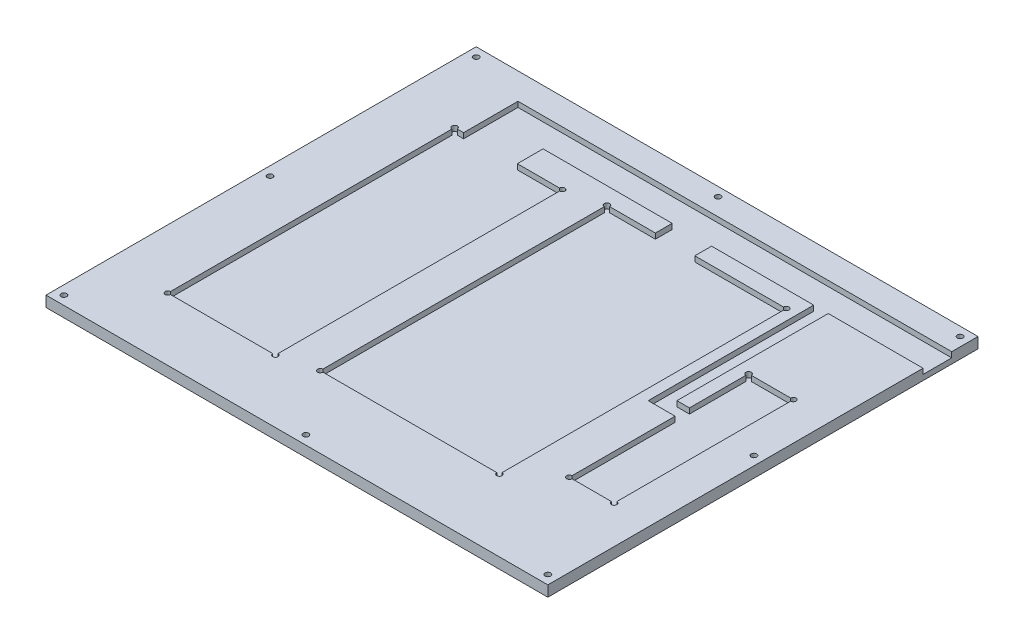
from build123d import *

# Parameters (mm, degrees)
SKETCH_1_W                  = 280
SKETCH_1_H                  = 240
EXTRUDE_1_DEPTH             = 6
HOLE_WIZARD_3_1_3_1_1_D     = 3.1
HOLE_WIZARD_3_1_3_1_1_DEPTH = 10
HOLE_WIZARD_3_1_3_1_1_TIP   = 0.931333959
SKETCH_7_R                  = 1.5
SKETCH_7_W                  = 25
SKETCH_7_H                  = 100
SKETCH_7_W_2                = 100
SKETCH_7_H_2                = 160
SKETCH_7_W_3                = 60
CUT_EXTRUDE_1_DEPTH         = 3
CUT_EXTRUDE_2_DEPTH         = 3


with BuildPart() as part:
    # Эскиз1 → Бобышка-Вытянуть1 (new body)
    with BuildSketch(Plane(origin=(0, 0, 0), x_dir=(1, 0, 0), z_dir=(0, 1, 0))):
        Rectangle(SKETCH_1_W, SKETCH_1_H)
    extrude(amount=EXTRUDE_1_DEPTH)

    # Диаметр отверстия Ø3.1 (3.1)1
    with Locations(Plane(origin=(0, 6, 0), x_dir=(1, 0, 0), z_dir=(0, 1, 0))):
        with Locations((-135, 115), (0, 115), (135, 115), (135, 0), (135, -115), (0, -115), (-135, -115), (-135, 0), (401.523177345, 110.995095939)):
            Hole(HOLE_WIZARD_3_1_3_1_1_D / 2, depth=HOLE_WIZARD_3_1_3_1_1_DEPTH)
            with Locations((0, 0, -(HOLE_WIZARD_3_1_3_1_1_DEPTH + HOLE_WIZARD_3_1_3_1_1_TIP / 2))):  # 118° drill point
                Cone(0, HOLE_WIZARD_3_1_3_1_1_D / 2, HOLE_WIZARD_3_1_3_1_1_TIP, mode=Mode.SUBTRACT)

    # Эскиз7 → Вырез-Вытянуть1 (cut)
    with BuildSketch(Plane(origin=(0, 6, 0), x_dir=(1, 0, 0), z_dir=(0, 1, 0))):
        with BuildLine():
            ThreePointArc((120.5, 38), (119, 39.5), (117.5, 38))
            Line((117.5, 38), (119, 38))
            Line((119, 38), (119, 36.5))
            ThreePointArc((119, 36.5), (120.060660172, 36.939339828), (120.5, 38))
        make_face()
        with BuildLine():
            Line((119, 38), (117.5, 38))
            ThreePointArc((117.5, 38), (117.939339828, 36.939339828), (119, 36.5))
            Line((119, 36.5), (119, 38))
        make_face()
        with Locations((94, 38)):
            Circle(SKETCH_7_R)
        with Locations((94, -62)):
            Circle(SKETCH_7_R)
        with Locations((119, -62)):
            Circle(SKETCH_7_R)
        with Locations((119, 38)):
            Circle(SKETCH_7_R)
        with Locations((106.5, -12)):
            Rectangle(SKETCH_7_W, SKETCH_7_H)
        with BuildLine():
            ThreePointArc((94, 36.5), (95.060660172, 36.939339828), (95.5, 38))
            Line((95.5, 38), (94, 38))
            Line((94, 38), (94, 36.5))
        make_face()
        with BuildLine():
            Line((94, 38), (95.5, 38))
            ThreePointArc((95.5, 38), (92.939339828, 39.060660172), (94, 36.5))
            Line((94, 36.5), (94, 38))
        make_face()
        with BuildLine():
            ThreePointArc((95.5, -62), (95.060660172, -60.939339828), (94, -60.5))
            Line((94, -60.5), (94, -62))
            Line((94, -62), (95.5, -62))
        make_face()
        with BuildLine():
            Line((94, -62), (94, -60.5))
            ThreePointArc((94, -60.5), (92.939339828, -63.060660172), (95.5, -62))
            Line((95.5, -62), (94, -62))
        make_face()
        with BuildLine():
            ThreePointArc((120.5, -62), (120.060660172, -60.939339828), (119, -60.5))
            Line((119, -60.5), (119, -62))
            Line((119, -62), (117.5, -62))
            ThreePointArc((117.5, -62), (119, -63.5), (120.5, -62))
        make_face()
        with BuildLine():
            Line((119, -62), (119, -60.5))
            ThreePointArc((119, -60.5), (117.939339828, -60.939339828), (117.5, -62))
            Line((117.5, -62), (119, -62))
        make_face()
        with Locations((-27, 80)):
            Circle(SKETCH_7_R)
        with Locations((-27, -80)):
            Circle(SKETCH_7_R)
        with Locations((73, -80)):
            Circle(SKETCH_7_R)
        with Locations((73, 80)):
            Circle(SKETCH_7_R)
        with Locations((23, 0)):
            Rectangle(SKETCH_7_W_2, SKETCH_7_H_2)
        with Locations((-107, -85)):
            Circle(SKETCH_7_R)
        with Locations((-47, -85)):
            Circle(SKETCH_7_R)
        with Locations((-47, 75)):
            Circle(SKETCH_7_R)
        with Locations((-107, 75)):
            Circle(SKETCH_7_R)
        with Locations((-77, -5)):
            Rectangle(SKETCH_7_W_3, SKETCH_7_H_2)
        with BuildLine():
            ThreePointArc((74.5, 80), (73, 81.5), (71.5, 80))
            Line((71.5, 80), (73, 80))
            Line((73, 80), (73, 78.5))
            ThreePointArc((73, 78.5), (74.060660172, 78.939339828), (74.5, 80))
        make_face()
        with BuildLine():
            Line((73, 80), (71.5, 80))
            ThreePointArc((71.5, 80), (71.939339828, 78.939339828), (73, 78.5))
            Line((73, 78.5), (73, 80))
        make_face()
        with BuildLine():
            ThreePointArc((74.5, -80), (74.060660172, -78.939339828), (73, -78.5))
            Line((73, -78.5), (73, -80))
            Line((73, -80), (71.5, -80))
            ThreePointArc((71.5, -80), (73, -81.5), (74.5, -80))
        make_face()
        with BuildLine():
            Line((73, -80), (73, -78.5))
            ThreePointArc((73, -78.5), (71.939339828, -78.939339828), (71.5, -80))
            Line((71.5, -80), (73, -80))
        make_face()
        with BuildLine():
            ThreePointArc((-25.5, -80), (-25.939339828, -78.939339828), (-27, -78.5))
            Line((-27, -78.5), (-27, -80))
            Line((-27, -80), (-25.5, -80))
        make_face()
        with BuildLine():
            Line((-27, -80), (-27, -78.5))
            ThreePointArc((-27, -78.5), (-28.060660172, -81.060660172), (-25.5, -80))
            Line((-25.5, -80), (-27, -80))
        make_face()
        with BuildLine():
            ThreePointArc((-27, 78.5), (-25.939339828, 78.939339828), (-25.5, 80))
            Line((-25.5, 80), (-27, 80))
            Line((-27, 80), (-27, 78.5))
        make_face()
        with BuildLine():
            Line((-27, 80), (-25.5, 80))
            ThreePointArc((-25.5, 80), (-28.060660172, 81.060660172), (-27, 78.5))
            Line((-27, 78.5), (-27, 80))
        make_face()
        with BuildLine():
            ThreePointArc((-45.5, 75), (-47, 76.5), (-48.5, 75))
            Line((-48.5, 75), (-47, 75))
            Line((-47, 75), (-47, 73.5))
            ThreePointArc((-47, 73.5), (-45.939339828, 73.939339828), (-45.5, 75))
        make_face()
        with BuildLine():
            Line((-47, 75), (-48.5, 75))
            ThreePointArc((-48.5, 75), (-48.060660172, 73.939339828), (-47, 73.5))
            Line((-47, 73.5), (-47, 75))
        make_face()
        with BuildLine():
            ThreePointArc((-45.5, -85), (-45.939339828, -83.939339828), (-47, -83.5))
            Line((-47, -83.5), (-47, -85))
            Line((-47, -85), (-48.5, -85))
            ThreePointArc((-48.5, -85), (-47, -86.5), (-45.5, -85))
        make_face()
        with BuildLine():
            Line((-47, -85), (-47, -83.5))
            ThreePointArc((-47, -83.5), (-48.060660172, -83.939339828), (-48.5, -85))
            Line((-48.5, -85), (-47, -85))
        make_face()
        with BuildLine():
            ThreePointArc((-105.5, -85), (-105.939339828, -83.939339828), (-107, -83.5))
            Line((-107, -83.5), (-107, -85))
            Line((-107, -85), (-105.5, -85))
        make_face()
        with BuildLine():
            Line((-107, -85), (-107, -83.5))
            ThreePointArc((-107, -83.5), (-108.060660172, -86.060660172), (-105.5, -85))
            Line((-105.5, -85), (-107, -85))
        make_face()
        with BuildLine():
            ThreePointArc((-107, 73.5), (-105.939339828, 73.939339828), (-105.5, 75))
            Line((-105.5, 75), (-107, 75))
            Line((-107, 75), (-107, 73.5))
        make_face()
        with BuildLine():
            Line((-107, 75), (-105.5, 75))
            ThreePointArc((-105.5, 75), (-108.060660172, 76.060660172), (-107, 73.5))
            Line((-107, 73.5), (-107, 75))
        make_face()
    extrude(amount=-CUT_EXTRUDE_1_DEPTH, mode=Mode.SUBTRACT)

    # Эскиз8 → Вырез-Вытянуть2 (cut)
    with BuildSketch(Plane(origin=(0, 6, 0), x_dir=(1, 0, 0), z_dir=(0, 1, 0))):
        Polygon((87.121057206, 89.335537533), (140, 89.335537533), (140, 105.335537533), (22, 105.335537533), (-42.979723536, 105.335537533), (-102, 105.335537533), (-102, 89.335537533), (-102, 75), (-72, 75), (-72, 89.335537533), (0, 89.335537533), (0, 80), (22, 80), (22.024724926, 89.335537533), (79, 89.335537533), (79, -3), (94, -3), (94, 5), (87, 5), align=None)
    extrude(amount=-CUT_EXTRUDE_2_DEPTH, mode=Mode.SUBTRACT)


solid = part.part
